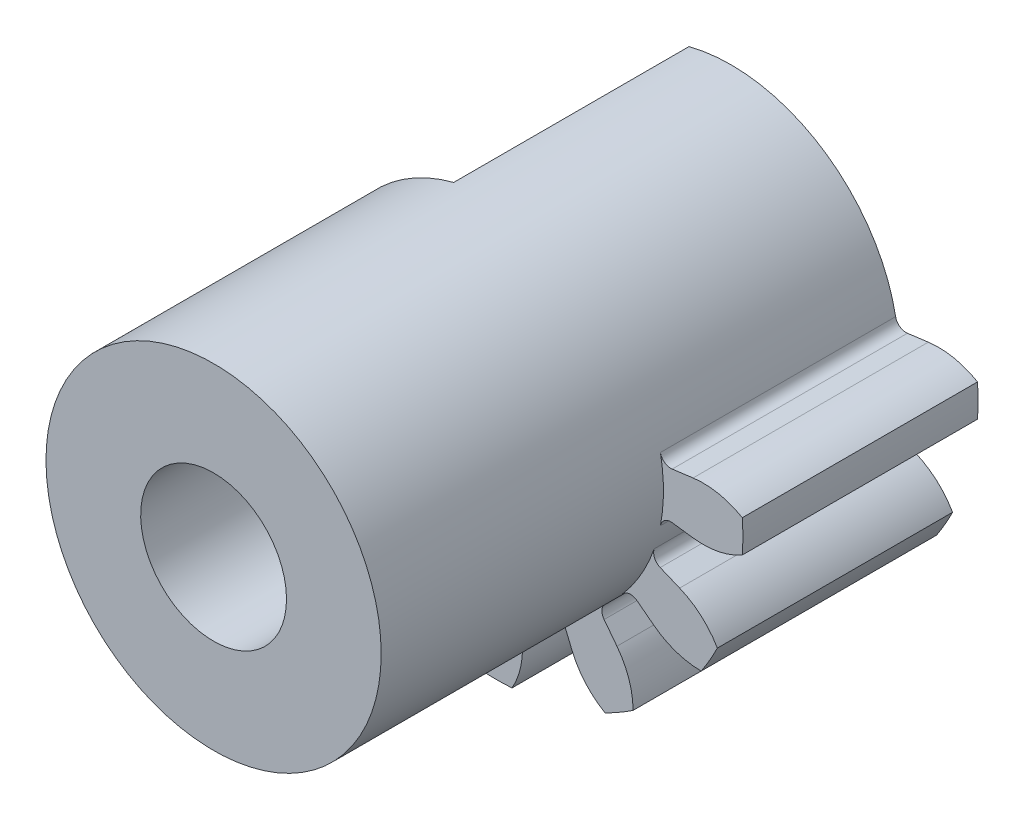
from build123d import *

# Parameters (mm, degrees)
MAINGEAR_DEPTH                     = 10
CONG_1_R                           = 0.45
R_P_TITION_CIRCULAIRE1_COUNT       = 4
R_P_TITION_CIRCULAIRE1_ANGLE       = 90
CONG_1_OF_R_P_TITION_CIRCULAIRE1_R = 0.45
ESQUISSE5_R                        = 7.125
MAINBASECIRCLE_DEPTH               = 10
REMOVEGEARTOP_DEPTH                = 10
ESQUISSE9_R                        = 7.125
ESQUISSE9_R_2                      = 3.1
GEARBOTTOMFIX_DEPTH                = 12
ESQUISSE3_R                        = 3.1
GEARHOLE_DEPTH                     = 23
MEPLATHOLE_DEPTH                   = 15


with BuildPart() as part:
    # Esquisse1 → MainGear (new body)
    with BuildSketch(Plane.XY):
        with BuildLine():
            Line((0, 0), (6.882221512, 1.844085696))
            ThreePointArc((6.882221512, 1.844085696), (6.988095123, 1.390018544), (7.064044637, 0.92999912))
            Line((7.064044637, 0.92999912), (8.384880781, 1.103890497))
            ThreePointArc((8.384880781, 1.103890497), (9.465680859, 1.068283463), (10.477518694, 0.686732857))
            ThreePointArc((10.477518694, 0.686732857), (10.5, 0), (10.477518694, -0.686732857))
            ThreePointArc((10.477518694, -0.686732857), (9.465680859, -1.068283463), (8.384880781, -1.103890497))
            Line((8.384880781, -1.103890497), (7.064044637, -0.92999912))
            ThreePointArc((7.064044637, -0.92999912), (6.988095123, -1.390018544), (6.882221512, -1.844085696))
            Line((6.882221512, -1.844085696), (0, 0))
        make_face()
    maingear = extrude(amount=MAINGEAR_DEPTH)

    # Cong_1
    cong_1_edges = [part.edges().sort_by_distance(p)[0] for p in [
        (7.064044637, 0.92999912, 5),
        (7.064044637, -0.92999912, 5),
    ]]
    fillet(cong_1_edges, radius=CONG_1_R)

    # R_p_tition circulaire1: MainGear ×4 about axis
    r_p_tition_circulaire1_axis = Axis((0, 0, 0), (0, 0, -1))
    for i in range(1, R_P_TITION_CIRCULAIRE1_COUNT):
        add(maingear.rotate(r_p_tition_circulaire1_axis, i * R_P_TITION_CIRCULAIRE1_ANGLE / (R_P_TITION_CIRCULAIRE1_COUNT - 1)))

    # Cong_1 of R_p_tition circulaire1
    cong_1_of_r_p_tition_circulaire1_edges = [part.edges().sort_by_distance(p)[0] for p in [
        (6.582641669, -2.726619456, 5),
        (5.65264255, -4.337425182, 5),
        (4.337425182, -5.65264255, 5),
        (2.726619456, -6.582641669, 5),
        (0.92999912, -7.064044637, 5),
        (-0.92999912, -7.064044637, 5),
    ]]
    fillet(cong_1_of_r_p_tition_circulaire1_edges, radius=CONG_1_OF_R_P_TITION_CIRCULAIRE1_R)

    # Esquisse9 → GearBottomFix (add)
    with BuildSketch(Plane.XY.offset(10)):
        Circle(ESQUISSE9_R)
        Circle(ESQUISSE9_R_2, mode=Mode.SUBTRACT)
    extrude(amount=GEARBOTTOMFIX_DEPTH)


with BuildPart() as body_2:
    # Esquisse5 → MainBaseCircle (new body, through all)
    with BuildSketch(Plane.XY.offset(10)):
        Circle(ESQUISSE5_R)
    extrude(amount=-MAINBASECIRCLE_DEPTH)

    # Esquisse7 → RemoveGearTop (cut)
    with BuildSketch(Plane.XY.offset(10)):
        with BuildLine():
            Line((-6.868119582, -1.895932068), (-1.792134456, 6.895932068))
            ThreePointArc((-1.792134456, 6.895932068), (-6.170431002, 3.5625), (-6.868119582, -1.895932068))
        make_face()
    extrude(amount=-REMOVEGEARTOP_DEPTH, mode=Mode.SUBTRACT)


with BuildPart() as gearhole_tool:
    # Esquisse3 → GearHole (new body, through all)
    with BuildSketch(Plane.XY):
        Circle(ESQUISSE3_R)
    extrude(amount=GEARHOLE_DEPTH)


with BuildPart() as part_1:
    add(part.part)

    # GearHole: cut by gearhole_tool
    add(gearhole_tool.part, mode=Mode.SUBTRACT)



with BuildPart() as body_2_1:
    add(body_2.part)

    # GearHole: cut by gearhole_tool
    add(gearhole_tool.part, mode=Mode.SUBTRACT)


with BuildPart() as part_2:
    add(part_1.part)

    add(body_2_1.part)  # MeplatHole merges body 2
    # Esquisse10 → MeplatHole (add)
    with BuildSketch(Plane(origin=(0, 0, 0), x_dir=(-1, 0, 0), z_dir=(0, 0, -1))):
        with BuildLine():
            Line((-1.24854837, -2.837450787), (-3.081578648, 0.337450787))
            ThreePointArc((-3.081578648, 0.337450787), (-2.684678752, -1.55), (-1.24854837, -2.837450787))
        make_face()
    extrude(amount=-MEPLATHOLE_DEPTH)


solid = part_2.part
